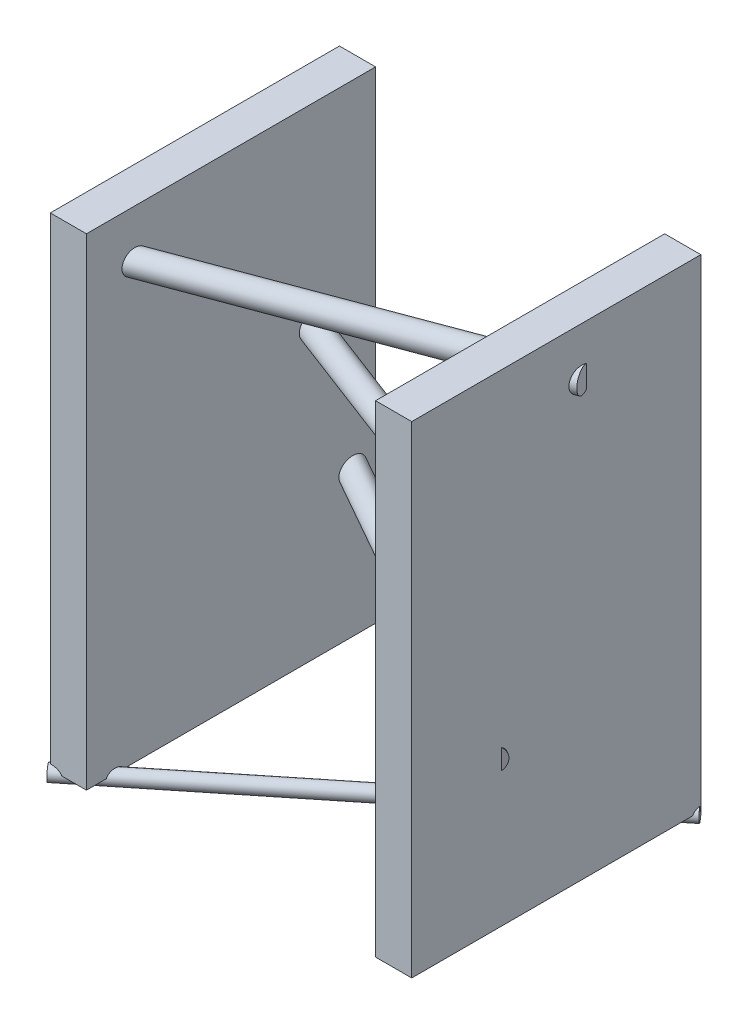
from build123d import *

# Parameters (mm, degrees)
SKETCH_1_W          = 1500
SKETCH_1_H          = 2000
EXTRUDE_1_DEPTH     = 1200
SKETCH_2_W          = 1200
SKETCH_2_H          = 1200
CUT_EXTRUDE_1_DEPTH = 2000
SWEEP_1_PROFILE_R   = 30
SWEEP_2_PROFILE_R   = 50
SWEEP_3_PROFILE_R   = 50
SWEEP_4_PROFILE_R   = 50


with BuildPart() as part:
    # ｽｹｯﾁ1 → ﾎﾞｽ - 押し出し1 (new body)
    with BuildSketch(Plane.XY):
        Rectangle(SKETCH_1_W, SKETCH_1_H)
    extrude(amount=EXTRUDE_1_DEPTH)

    # ｽｹｯﾁ2 → ｶｯﾄ - 押し出し1 (cut)
    with BuildSketch(Plane.XZ.offset(1000)):
        with Locations((0, 600)):
            Rectangle(SKETCH_2_W, SKETCH_2_H)
    extrude(amount=-CUT_EXTRUDE_1_DEPTH, mode=Mode.SUBTRACT)

    # ｽｲｰﾌﾟ1: sweep along a path in ｽｹｯﾁ5
    with BuildLine(Plane(origin=(0, -1010, 0), x_dir=(-1, 0, 0), z_dir=(0, -1, 0))) as sweep_1_path:
        Line((-746.509913614, 0), (754.169659327, -1205.37673669))
    # ｽｲｰﾌﾟ1 profile (on start of the path) → ｽｲｰﾌﾟ1 (sweep)
    with BuildSketch(Plane(origin=(746.509913614, -1010, 0), x_dir=(-0.62622489, 0, -0.779642474), z_dir=(-0.779642474, 0, 0.62622489))):
        Circle(SWEEP_1_PROFILE_R)
    sweep(path=sweep_1_path.line)

    # ｽｲｰﾌﾟ2: sweep along a path in ｽｹｯﾁ6
    with BuildLine(Plane(origin=(0, -400, 0), x_dir=(-1, 0, 0), z_dir=(0, -1, 0))) as sweep_2_path:
        Line((-736.327324349, -851.094641134), (767.889088403, 0))
    # ｽｲｰﾌﾟ2 profile (on start of the path) → ｽｲｰﾌﾟ2 (sweep)
    with BuildSketch(Plane(origin=(736.327324349, -400, 851.094641134), x_dir=(0.49244545, 0, -0.870343311), z_dir=(-0.870343311, 0, -0.49244545))):
        Circle(SWEEP_2_PROFILE_R)
    sweep(path=sweep_2_path.line)

    # ｽｲｰﾌﾟ3: sweep along a path in ｽｹｯﾁ35
    with BuildLine(Plane(origin=(0, 800, 0), x_dir=(-1, 0, 0), z_dir=(0, -1, 0))) as sweep_3_path:
        Line((-756.203731204, -491.849776028), (758.570800051, -1058.383412401))
    # ｽｲｰﾌﾟ3 profile (on start of the path) → ｽｲｰﾌﾟ3 (sweep)
    with BuildSketch(Plane(origin=(756.203731204, 800, 491.849776028), x_dir=(-0.350306464, 0, -0.936635138), z_dir=(-0.936635138, 0, 0.350306464))):
        Circle(SWEEP_3_PROFILE_R)
    sweep(path=sweep_3_path.line)

    # ｽｲｰﾌﾟ4: sweep along a path in ｽｹｯﾁ50
    with BuildLine(Plane(origin=(0, 200, 0), x_dir=(-1, 0, 0), z_dir=(0, -1, 0))) as sweep_4_path:
        Line((-726.41911479, -768.680681773), (692.023773595, -228.12926873))
    # ｽｲｰﾌﾟ4 profile (on start of the path) → ｽｲｰﾌﾟ4 (sweep)
    with BuildSketch(Plane(origin=(726.41911479, 200, 768.680681773), x_dir=(0.356105907, 0, -0.934445602), z_dir=(-0.934445602, 0, -0.356105907))):
        Circle(SWEEP_4_PROFILE_R)
    sweep(path=sweep_4_path.line)


solid = part.part
